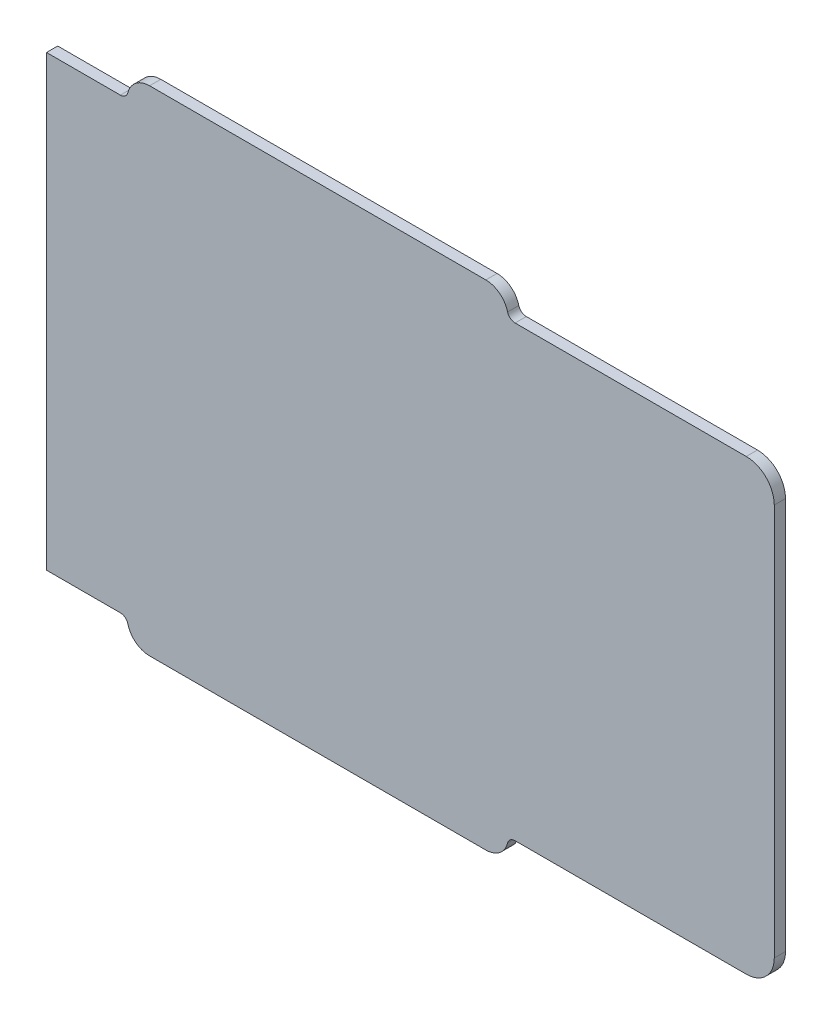
from build123d import *

# Parameters (mm, degrees)
BOSS_EXTRUDE1_DEPTH = 4
SKETCH2_R           = 2.75
CUT_EXTRUDE1_DEPTH  = 3
SKETCH3_R           = 2.35
BOSS_EXTRUDE2_DEPTH = 4
CHAMFER1_SIZE       = 1
CUT_EXTRUDE2_DEPTH  = 2.5
SKETCH6_W           = 2.7
SKETCH6_H           = 2.7
BOSS_EXTRUDE3_DEPTH = 4
CHAMFER2_SIZE       = 0.74


with BuildPart() as part:
    # Sketch1 → Boss-Extrude1 (new body)
    with BuildSketch(Plane.XY):
        with BuildLine():
            Line((120.3, 160), (146.661746787, 160))
            ThreePointArc((146.661746787, 160), (148.349682778, 160.578969808), (149.32688133, 162.072093023))
            ThreePointArc((149.32688133, 162.072093023), (152.169640756, 166.415724194), (157.08, 168.1))
            Line((157.08, 168.1), (277.08, 168.1))
            ThreePointArc((277.08, 168.1), (281.990359244, 166.415724194), (284.83311867, 162.072093023))
            ThreePointArc((284.83311867, 162.072093023), (285.810317222, 160.578969808), (287.498253213, 160))
            Line((287.498253213, 160), (370, 160))
            ThreePointArc((370, 160), (377.071067812, 157.071067812), (380, 150))
            Line((380, 150), (380, 10))
            ThreePointArc((380, 10), (377.071067812, 2.928932188), (370, 0))
            Line((370, 0), (287.498253213, 0))
            ThreePointArc((287.498253213, 0), (285.810317222, -0.578969808), (284.83311867, -2.072093023))
            ThreePointArc((284.83311867, -2.072093023), (281.990359244, -6.415724194), (277.08, -8.1))
            Line((277.08, -8.1), (157.08, -8.1))
            ThreePointArc((157.08, -8.1), (152.169640756, -6.415724194), (149.32688133, -2.072093023))
            ThreePointArc((149.32688133, -2.072093023), (148.349682778, -0.578969808), (146.661746787, 0))
            Line((146.661746787, 0), (120.3, 0))
            Line((120.3, 0), (120.3, 160))
        make_face()
    extrude(amount=BOSS_EXTRUDE1_DEPTH)

    # Sketch2 → Cut-Extrude1 (cut)
    with BuildSketch(Plane(origin=(0, 0, 0), x_dir=(-1, 0, 0), z_dir=(0, 0, -1))):
        with Locations((-126.25, 8.75)):
            Circle(SKETCH2_R)
        with Locations((-126.25, 151.25)):
            Circle(SKETCH2_R)
        with Locations((-370, 10)):
            Circle(SKETCH2_R)
        with Locations((-370, 150)):
            Circle(SKETCH2_R)
    extrude(amount=-CUT_EXTRUDE1_DEPTH, mode=Mode.SUBTRACT)

    # Sketch3 → Boss-Extrude2 (add)
    with BuildSketch(Plane(origin=(0, 0, 0), x_dir=(-1, 0, 0), z_dir=(0, 0, -1))):
        with Locations((-157.08, -0.1)):
            Circle(SKETCH3_R)
        with Locations((-157.08, 160.1)):
            Circle(SKETCH3_R)
        with Locations((-277.08, 160.1)):
            Circle(SKETCH3_R)
        with Locations((-277.08, -0.1)):
            Circle(SKETCH3_R)
    extrude(amount=BOSS_EXTRUDE2_DEPTH)

    # Chamfer1
    chamfer1_edges = [part.edges().sort_by_distance(p)[0] for p in [
        (159.43, -0.1, -4),
        (159.43, 160.1, -4),
        (279.43, 160.1, -4),
        (279.43, -0.1, -4),
    ]]
    chamfer(chamfer1_edges, length=CHAMFER1_SIZE)

    # Sketch4 → Cut-Extrude2 (cut)
    with BuildSketch(Plane(origin=(0, 0, 0), x_dir=(-1, 0, 0), z_dir=(0, 0, -1))):
        with BuildLine():
            ThreePointArc((-370, 15.75), (-365.934136008, 14.065863992), (-364.25, 10))
            Line((-364.25, 10), (-364.25, 3))
            Line((-364.25, 3), (-272.08, 3))
            Line((-272.08, 3), (-272.08, -5.1))
            Line((-272.08, -5.1), (-162.08, -5.1))
            Line((-162.08, -5.1), (-162.08, 3))
            Line((-162.08, 3), (-132, 3))
            Line((-132, 3), (-132, 8.75))
            ThreePointArc((-132, 8.75), (-130.315863992, 12.815863992), (-126.25, 14.5))
            Line((-126.25, 14.5), (-122.867487478, 14.5))
            Line((-122.867487478, 14.5), (-122.867487478, 145.5))
            Line((-122.867487478, 145.5), (-126.25, 145.5))
            ThreePointArc((-126.25, 145.5), (-130.315863992, 147.184136008), (-132, 151.25))
            Line((-132, 151.25), (-132, 157))
            Line((-132, 157), (-162.08, 157))
            Line((-162.08, 157), (-162.08, 165.1))
            Line((-162.08, 165.1), (-272.08, 165.1))
            Line((-272.08, 165.1), (-272.08, 157))
            Line((-272.08, 157), (-364.25, 157))
            Line((-364.25, 157), (-364.25, 150))
            ThreePointArc((-364.25, 150), (-365.934136008, 145.934136008), (-370, 144.25))
            Line((-370, 144.25), (-374, 144.25))
            Line((-374, 144.25), (-374, 141.25))
            Line((-374, 141.25), (-377, 141.25))
            Line((-377, 141.25), (-377, 18.75))
            Line((-377, 18.75), (-374, 18.75))
            Line((-374, 18.75), (-374, 15.75))
            Line((-374, 15.75), (-370, 15.75))
        make_face()
    extrude(amount=-CUT_EXTRUDE2_DEPTH, mode=Mode.SUBTRACT)

    # Sketch6 → Boss-Extrude3 (add)
    with BuildSketch(Plane(origin=(0, 0, 0), x_dir=(-1, 0, 0), z_dir=(0, 0, -1))):
        with Locations((-375.35, 17.4)):
            Rectangle(SKETCH6_W, SKETCH6_H)
        with Locations((-375.35, 142.6)):
            Rectangle(SKETCH6_W, SKETCH6_H)
    extrude(amount=BOSS_EXTRUDE3_DEPTH)

    # Chamfer2
    chamfer2_edges = [part.edges().sort_by_distance(p)[0] for p in [
        (376.7, 16.05, -2),
        (376.7, 17.4, -4),
        (375.35, 16.05, -4),
        (376.7, 143.95, -2),
        (375.35, 143.95, -4),
        (376.7, 142.6, -4),
    ]]
    chamfer(chamfer2_edges, length=CHAMFER2_SIZE)


solid = part.part
